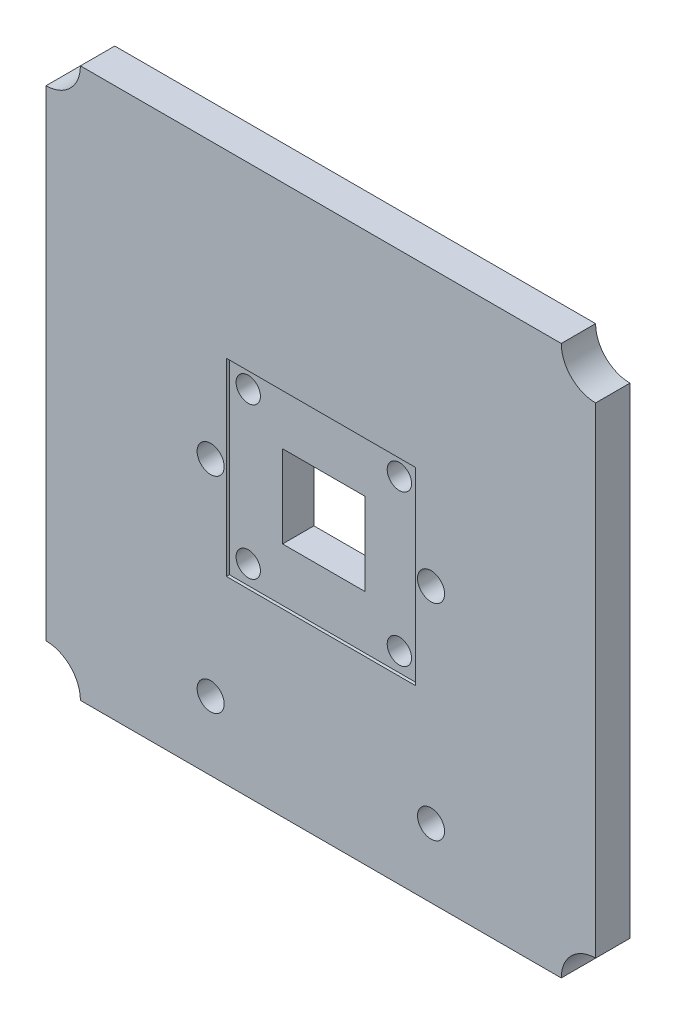
from build123d import *

# Parameters (mm, degrees)
SKETCH1_W                              = 114.3
SKETCH1_H                              = 114.3
BOSS_EXTRUDE1_DEPTH                    = 53.975
CUT_EXTRUDE1_DEPTH                     = 101.6
SKETCH5_W                              = 34.94
SKETCH5_H                              = 34.94
SKETCH5_W_2                            = 15.25
SKETCH5_H_2                            = 15.25
CUT_EXTRUDE5_DEPTH                     = 0.55
CUT_EXTRUDE6_REACH                     = 135.539
SKETCH5_3_W                            = 15.25
SKETCH5_3_H                            = 15.25
SKETCH13_R                             = 2.54
BOSS_EXTRUDE2_DEPTH                    = 1.27
SKETCH13_4_R                           = 2.54
CUT_EXTRUDE7_DEPTH                     = 2.54
CUT_EXTRUDE8_DEPTH                     = 0.635
CUT_EXTRUDE9_DEPTH                     = 1.27
CBORE_FOR_M5_HEX_HEAD_BOLT2_AT_2_COUNT = 2
CBORE_FOR_M5_HEX_HEAD_BOLT2_AT_2_PITCH = 27.94
CBORE_FOR_M5_HEX_HEAD_BOLT2_AT_3_COUNT = 2
CBORE_FOR_M5_HEX_HEAD_BOLT2_AT_3_PITCH = 39.513126933
CBORE_FOR_M5_HEX_HEAD_BOLT2_AT_4_COUNT = 2
CBORE_FOR_M5_HEX_HEAD_BOLT2_AT_4_PITCH = 27.94
CUT_EXTRUDE10_START                    = -2.032
CUT_EXTRUDE10_DEPTH                    = 2.032
CIRPATTERN1_COUNT                      = 4
SKETCH26_W                             = 114.3
SKETCH26_H                             = 107.95
CUT_EXTRUDE11_DEPTH                    = 107.95
CUT_EXTRUDE12_REACH                    = 80.865
SKETCH27_R                             = 2.5
CUT_EXTRUDE13_DEPTH                    = 6.35


with BuildPart() as part:
    # Sketch1 → Boss-Extrude1 (new, symmetric)
    with BuildSketch(Plane(origin=(0, 0, 0), x_dir=(1, 0, 0), z_dir=(0, 1, 0))):
        Rectangle(SKETCH1_W, SKETCH1_H)
    extrude(amount=BOSS_EXTRUDE1_DEPTH, both=True)

    # Sketch2 → Cut-Extrude1 (cut)
    with BuildSketch(Plane(origin=(0, 53.975, 0), x_dir=(1, 0, 0), z_dir=(0, 1, 0))):
        with BuildLine():
            Line((44.45, 50.8), (-44.45, 50.8))
            ThreePointArc((-44.45, 50.8), (-46.309871939, 46.309871939), (-50.8, 44.45))
            Line((-50.8, 44.45), (-50.8, -44.45))
            ThreePointArc((-50.8, -44.45), (-46.309871939, -46.309871939), (-44.45, -50.8))
            Line((-44.45, -50.8), (44.45, -50.8))
            ThreePointArc((44.45, -50.8), (46.309871939, -46.309871939), (50.8, -44.45))
            Line((50.8, -44.45), (50.8, 44.45))
            ThreePointArc((50.8, 44.45), (46.309871939, 46.309871939), (44.45, 50.8))
        make_face()
    extrude(amount=-CUT_EXTRUDE1_DEPTH, mode=Mode.SUBTRACT)

    # Sketch5 → Cut-Extrude5 (cut)
    with BuildSketch(Plane.XY.offset(-50.8)):
        with Locations((0, 3.185)):
            Rectangle(SKETCH5_W, SKETCH5_H)
        with Locations((0, 3.185)):
            Rectangle(SKETCH5_W_2, SKETCH5_H_2, mode=Mode.SUBTRACT)
    extrude(amount=-CUT_EXTRUDE5_DEPTH, mode=Mode.SUBTRACT)

    # Sketch5_3 → Cut-Extrude6 (cut, up to next)
    with BuildSketch(Plane.XY.offset(-50.8), mode=Mode.PRIVATE) as cut_extrude6_sk1:
        with Locations((0, 3.185)):
            Rectangle(SKETCH5_3_W, SKETCH5_3_H)
    cut_extrude6_tool1 = extrude(cut_extrude6_sk1.sketch, amount=-CUT_EXTRUDE6_REACH, mode=Mode.PRIVATE) & part.part
    add(cut_extrude6_tool1.solids().sort_by_distance((0, 3.185, -50.8))[0], mode=Mode.SUBTRACT)

    # Sketch13 → Boss-Extrude2 (add)
    with BuildSketch(Plane(origin=(0, 0, -57.15), x_dir=(-1, 0, 0), z_dir=(0, 0, -1))):
        with Locations((-14.2875, 25.4)):
            Circle(SKETCH13_R)
    boss_extrude2 = extrude(amount=BOSS_EXTRUDE2_DEPTH)

    # Sketch14 → Revolve1 (revolve)
    with BuildSketch(Plane(origin=(14.2875, 25.4, -57.15), x_dir=(-1, 0, 0), z_dir=(0, -1, 0))):
        Polygon((0, 1.27), (0, 2.54), (2.286, 2.54), (2.64, 1.905), (2.64, 1.27), (2.54, 1.27), align=None)
    revolve1 = revolve(axis=Axis((14.2875, 25.4, -58.42), (0, 0, -1)))

    # Sketch13_4 → Cut-Extrude7 (cut)
    with BuildSketch(Plane(origin=(0, 0, -57.15), x_dir=(-1, 0, 0), z_dir=(0, 0, -1))):
        with Locations((14.2875, 25.4)):
            Circle(SKETCH13_4_R)
    cut_extrude7 = extrude(amount=-CUT_EXTRUDE7_DEPTH, mode=Mode.SUBTRACT)

    # Sketch13_5 → Cut-Extrude8 (cut)
    with BuildSketch(Plane(origin=(0, 0, -57.15), x_dir=(-1, 0, 0), z_dir=(0, 0, -1))):
        with BuildLine():
            Line((13.7875, 27.890301187), (13.7875, 29.177049113))
            ThreePointArc((13.7875, 29.177049113), (12.601161082, 28.816483726), (11.593423164, 28.094076836))
            Line((11.593423164, 28.094076836), (12.491448776, 27.196051224))
            ThreePointArc((12.491448776, 27.196051224), (13.088142439, 27.639004565), (13.7875, 27.890301187))
        make_face()
        with BuildLine():
            ThreePointArc((16.981576836, 28.094076836), (15.973838918, 28.816483726), (14.7875, 29.177049113))
            Line((14.7875, 29.177049113), (14.7875, 27.890301187))
            ThreePointArc((14.7875, 27.890301187), (15.486857561, 27.639004565), (16.083551224, 27.196051224))
            Line((16.083551224, 27.196051224), (16.981576836, 28.094076836))
        make_face()
        with BuildLine():
            Line((12.491448776, 23.603948776), (11.593423164, 22.705923164))
            ThreePointArc((11.593423164, 22.705923164), (12.601161082, 21.983516274), (13.7875, 21.622950887))
            Line((13.7875, 21.622950887), (13.7875, 22.909698813))
            ThreePointArc((13.7875, 22.909698813), (13.088142439, 23.160995435), (12.491448776, 23.603948776))
        make_face()
        with BuildLine():
            ThreePointArc((14.7875, 21.622950887), (15.973838918, 21.983516274), (16.981576836, 22.705923164))
            Line((16.981576836, 22.705923164), (16.083551224, 23.603948776))
            ThreePointArc((16.083551224, 23.603948776), (15.486857561, 23.160995435), (14.7875, 22.909698813))
            Line((14.7875, 22.909698813), (14.7875, 21.622950887))
        make_face()
    cut_extrude8 = extrude(amount=-CUT_EXTRUDE8_DEPTH, mode=Mode.SUBTRACT)

    # Sketch13_6 → Cut-Extrude9 (cut)
    with BuildSketch(Plane(origin=(0, 0, -57.15), x_dir=(-1, 0, 0), z_dir=(0, 0, -1))):
        with BuildLine():
            ThreePointArc((14.7875, 29.177049113), (14.2875, 29.21), (13.7875, 29.177049113))
            Line((13.7875, 29.177049113), (13.7875, 27.890301187))
            ThreePointArc((13.7875, 27.890301187), (14.2875, 27.94), (14.7875, 27.890301187))
            Line((14.7875, 27.890301187), (14.7875, 29.177049113))
        make_face()
        with BuildLine():
            Line((13.7875, 22.909698813), (13.7875, 21.622950887))
            ThreePointArc((13.7875, 21.622950887), (14.2875, 21.59), (14.7875, 21.622950887))
            Line((14.7875, 21.622950887), (14.7875, 22.909698813))
            ThreePointArc((14.7875, 22.909698813), (14.2875, 22.86), (13.7875, 22.909698813))
        make_face()
    cut_extrude9 = extrude(amount=-CUT_EXTRUDE9_DEPTH, mode=Mode.SUBTRACT)

    # Sketch17 → Cut-Revolve1 (revolve, cut)
    with BuildSketch(Plane(origin=(-14.2875, 25.4, -57.15), x_dir=(-1, 0, 0), z_dir=(0, -1, 0))):
        Polygon((0, -1.27), (0, -2.54), (2.286, -2.54), (2.64, -1.905), (2.64, -1.27), (2.54, -1.27), align=None)
    cut_revolve1 = revolve(axis=Axis((-14.2875, 25.4, -55.88), (0, 0, 1)), mode=Mode.SUBTRACT)

    # Sketch21 → CBORE for M5 Hex Head Bolt2 (revolve, cut)
    with BuildSketch(Plane(origin=(13.97, 17.155, -57.15), x_dir=(0, 1, 0), z_dir=(1, 0, 0))):
        Polygon((0, 0), (0, 18.288), (2.75, 16.635633298), (2.75, 5.8), (2.25, 5.8), (2.25, 0), align=None)
    cbore_for_m5_hex_head_bolt2 = revolve(axis=Axis((13.97, 17.155, -63.5), (0, 0, 1)), mode=Mode.SUBTRACT)

    # CBORE for M5 Hex Head Bolt2 at 2: CBORE for M5 Hex Head Bolt2 ×2
    with Locations(*[(-i * CBORE_FOR_M5_HEX_HEAD_BOLT2_AT_2_PITCH, 0, 0) for i in range(1, CBORE_FOR_M5_HEX_HEAD_BOLT2_AT_2_COUNT)]):
        add(cbore_for_m5_hex_head_bolt2, mode=Mode.SUBTRACT)

    # CBORE for M5 Hex Head Bolt2 at 3: CBORE for M5 Hex Head Bolt2 ×2
    with Locations(*[Vector(-0.7071067811865476, -0.7071067811865476, 0) * (i * CBORE_FOR_M5_HEX_HEAD_BOLT2_AT_3_PITCH) for i in range(1, CBORE_FOR_M5_HEX_HEAD_BOLT2_AT_3_COUNT)]):
        add(cbore_for_m5_hex_head_bolt2, mode=Mode.SUBTRACT)

    # CBORE for M5 Hex Head Bolt2 at 4: CBORE for M5 Hex Head Bolt2 ×2
    with Locations(*[(0, -i * CBORE_FOR_M5_HEX_HEAD_BOLT2_AT_4_PITCH, 0) for i in range(1, CBORE_FOR_M5_HEX_HEAD_BOLT2_AT_4_COUNT)]):
        add(cbore_for_m5_hex_head_bolt2, mode=Mode.SUBTRACT)

    # Sketch23 → Cut-Extrude10 (cut)
    with BuildSketch(Plane(origin=(0, 0, -59.69), x_dir=(-1, 0, 0), z_dir=(0, 0, -1)).offset(CUT_EXTRUDE10_START)):
        with BuildLine():
            Line((-14.7875, 27.992219127), (-14.7875, 22.807780873))
            ThreePointArc((-14.7875, 22.807780873), (-14.2875, 22.76), (-13.7875, 22.807780873))
            Line((-13.7875, 22.807780873), (-13.7875, 27.992219127))
            ThreePointArc((-13.7875, 27.992219127), (-14.2875, 28.04), (-14.7875, 27.992219127))
        make_face()
    cut_extrude10 = extrude(amount=CUT_EXTRUDE10_DEPTH, mode=Mode.SUBTRACT)

    # CirPattern1: Boss-Extrude2, Revolve1, Cut-Extrude7, Cut-Extrude8, Cut-Extrude9, Cut-Revolve1, Cut-Extrude10 ×4 about axis
    cirpattern1_axis = Axis((0, 3.185, 62.865), (0, 0, -1))
    add([boss_extrude2.rotate(cirpattern1_axis, i * 360 / CIRPATTERN1_COUNT) for i in range(1, CIRPATTERN1_COUNT)])
    add([revolve1.rotate(cirpattern1_axis, i * 360 / CIRPATTERN1_COUNT) for i in range(1, CIRPATTERN1_COUNT)])
    add([cut_extrude7.rotate(cirpattern1_axis, i * 360 / CIRPATTERN1_COUNT) for i in range(1, CIRPATTERN1_COUNT)], mode=Mode.SUBTRACT)
    add([cut_extrude8.rotate(cirpattern1_axis, i * 360 / CIRPATTERN1_COUNT) for i in range(1, CIRPATTERN1_COUNT)], mode=Mode.SUBTRACT)
    add([cut_extrude9.rotate(cirpattern1_axis, i * 360 / CIRPATTERN1_COUNT) for i in range(1, CIRPATTERN1_COUNT)], mode=Mode.SUBTRACT)
    add([cut_revolve1.rotate(cirpattern1_axis, i * 360 / CIRPATTERN1_COUNT) for i in range(1, CIRPATTERN1_COUNT)], mode=Mode.SUBTRACT)
    add([cut_extrude10.rotate(cirpattern1_axis, i * 360 / CIRPATTERN1_COUNT) for i in range(1, CIRPATTERN1_COUNT)], mode=Mode.SUBTRACT)

    # Sketch26 → Cut-Extrude11 (cut)
    with BuildSketch(Plane.XY.offset(57.15)):
        Rectangle(SKETCH26_W, SKETCH26_H)
    extrude(amount=-CUT_EXTRUDE11_DEPTH, mode=Mode.SUBTRACT)

    # Sketch27 → Cut-Extrude12 (cut, up to next)
    with BuildSketch(Plane(origin=(0, 0, -57.15), x_dir=(-1, 0, 0), z_dir=(0, 0, -1)), mode=Mode.PRIVATE) as cut_extrude12_sk1:
        with Locations((-20.375, 3.075)):
            Circle(SKETCH27_R)
    cut_extrude12_tool1 = extrude(cut_extrude12_sk1.sketch, amount=-CUT_EXTRUDE12_REACH, mode=Mode.PRIVATE) & part.part
    # Sketch27 → Cut-Extrude12 (cut, up to next)
    with BuildSketch(Plane(origin=(0, 0, -57.15), x_dir=(-1, 0, 0), z_dir=(0, 0, -1)), mode=Mode.PRIVATE) as cut_extrude12_sk2:
        with Locations((20.375, 3.075)):
            Circle(SKETCH27_R)
    cut_extrude12_tool2 = extrude(cut_extrude12_sk2.sketch, amount=-CUT_EXTRUDE12_REACH, mode=Mode.PRIVATE) & part.part
    # Sketch27 → Cut-Extrude12 (cut, up to next)
    with BuildSketch(Plane(origin=(0, 0, -57.15), x_dir=(-1, 0, 0), z_dir=(0, 0, -1)), mode=Mode.PRIVATE) as cut_extrude12_sk3:
        with Locations((20.375, -34.925)):
            Circle(SKETCH27_R)
    cut_extrude12_tool3 = extrude(cut_extrude12_sk3.sketch, amount=-CUT_EXTRUDE12_REACH, mode=Mode.PRIVATE) & part.part
    # Sketch27 → Cut-Extrude12 (cut, up to next)
    with BuildSketch(Plane(origin=(0, 0, -57.15), x_dir=(-1, 0, 0), z_dir=(0, 0, -1)), mode=Mode.PRIVATE) as cut_extrude12_sk4:
        with Locations((-20.375, -34.925)):
            Circle(SKETCH27_R)
    cut_extrude12_tool4 = extrude(cut_extrude12_sk4.sketch, amount=-CUT_EXTRUDE12_REACH, mode=Mode.PRIVATE) & part.part
    add(cut_extrude12_tool1.solids().sort_by_distance((20.375, 3.075, -57.15))[0], mode=Mode.SUBTRACT)
    add(cut_extrude12_tool2.solids().sort_by_distance((-20.375, 3.075, -57.15))[0], mode=Mode.SUBTRACT)
    add(cut_extrude12_tool3.solids().sort_by_distance((-20.375, -34.925, -57.15))[0], mode=Mode.SUBTRACT)
    add(cut_extrude12_tool4.solids().sort_by_distance((20.375, -34.925, -57.15))[0], mode=Mode.SUBTRACT)

    # Sketch29 → Cut-Extrude13 (cut)
    with BuildSketch(Plane(origin=(0, 0, -57.15), x_dir=(-1, 0, 0), z_dir=(0, 0, -1))):
        with BuildLine():
            Line((-44.45, 53.975), (-57.15, 53.975))
            Line((-57.15, 53.975), (-57.15, -53.975))
            Line((-57.15, -53.975), (57.15, -53.975))
            Line((57.15, -53.975), (57.15, 53.975))
            Line((57.15, 53.975), (44.45, 53.975))
            ThreePointArc((44.45, 53.975), (46.309871939, 49.484871939), (50.8, 47.625))
            Line((50.8, 47.625), (50.8, -41.275))
            ThreePointArc((50.8, -41.275), (46.309871939, -43.134871939), (44.45, -47.625))
            Line((44.45, -47.625), (-44.45, -47.625))
            ThreePointArc((-44.45, -47.625), (-46.309871939, -43.134871939), (-50.8, -41.275))
            Line((-50.8, -41.275), (-50.8, 47.625))
            ThreePointArc((-50.8, 47.625), (-46.309871939, 49.484871939), (-44.45, 53.975))
        make_face()
    extrude(amount=-CUT_EXTRUDE13_DEPTH, mode=Mode.SUBTRACT)


solid = part.part
